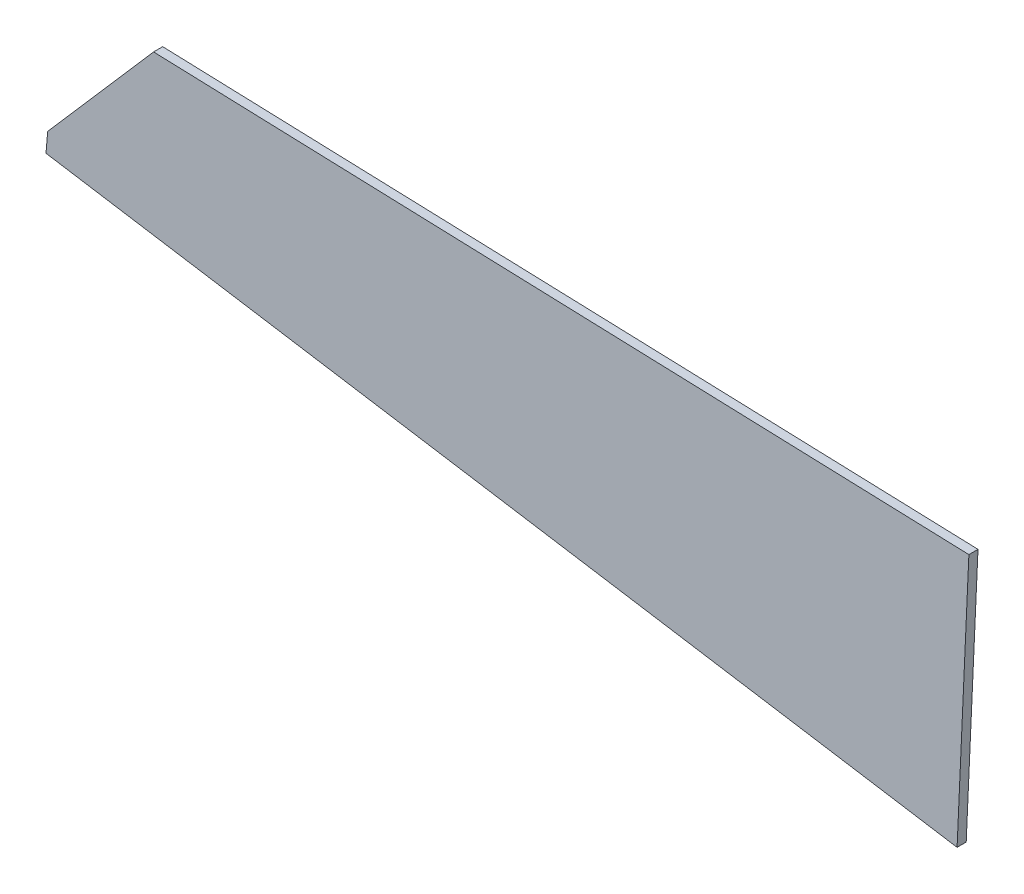
from build123d import *

# Parameters (mm, degrees)
BOSS_EXTRU_1_DEPTH = 3


with BuildPart() as part:
    # Esquisse1 → Boss.-Extru.1 (new body)
    with BuildSketch(Plane.XY):
        Polygon((215.474767364, 90.148242088), (480.765805083, 81.13860392), (483.765805083, 81.03671991), (479.882070142, -4.338370069), (180.077745423, 43.556471149), (180.640284286, 50.105407267), align=None)
    extrude(amount=BOSS_EXTRU_1_DEPTH)


solid = part.part
